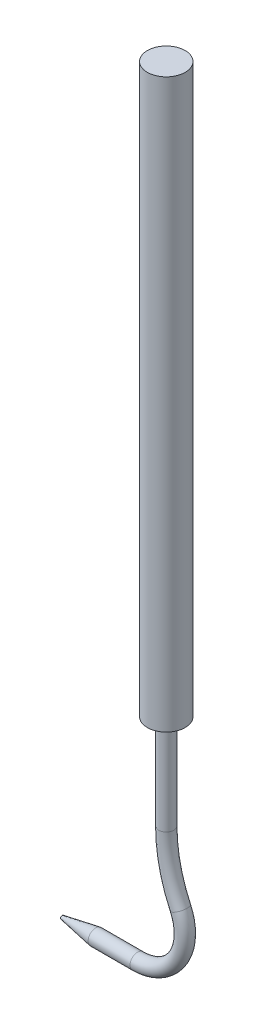
from build123d import *

# Parameters (mm, degrees)
SKETCH2_R               = 0.5
CUT_EXTRUDE1_DEPTH      = 4.052867504
CUT_EXTRUDE1_DEPTH_BACK = 4.052867504
SKETCH3_R               = 0.4
SKETCH5_R               = 1
BOSS_EXTRUDE1_DEPTH     = 30


with BuildPart() as part:
    # Sketch1 → Revolve1 (revolve)
    with BuildSketch(Plane.XY, mode=Mode.PRIVATE) as revolve1_sk:
        Polygon((0, 0), (3, 0), (3, -0.4), (2.268512728, -0.4), align=None)
    revolve(revolve1_sk.sketch.rotate(Axis((0, 0, 0), (-1, 0, 0)), 180), axis=Axis((0, 0, 0), (-1, 0, 0)))

    # Sketch2 → Cut-Extrude1 (cut, two sides)
    with BuildSketch(Plane(origin=(0, 0, 0), x_dir=(1, 0, 0), z_dir=(0, 1, 0))) as cut_extrude1_sk:
        Circle(SKETCH2_R)
    extrude(amount=CUT_EXTRUDE1_DEPTH, mode=Mode.SUBTRACT)
    extrude(cut_extrude1_sk.sketch, amount=-CUT_EXTRUDE1_DEPTH_BACK, mode=Mode.SUBTRACT)

    # Sweep1: sweep along a path in Sketch4
    with BuildLine(Plane.XY) as sweep1_path:
        Line((3, 0), (4.483768236, 0))
        ThreePointArc((4.483768236, 0), (6.592246851, 1.156750979), (6.749537704, 3.556545654))
        ThreePointArc((6.749537704, 3.556545654), (6.189631943, 5.205974837), (6, 6.937491748))
        Line((6, 6.937491748), (6, 11.937491748))
    # Sketch3 → Sweep1 (sweep)
    with BuildSketch(Plane(origin=(3, 0, 0), x_dir=(0, 0, -1), z_dir=(1, 0, 0))):
        Circle(SKETCH3_R)
    sweep(path=sweep1_path.line)

    # Sketch5 → Boss-Extrude1 (add)
    with BuildSketch(Plane(origin=(0, 11.937491748, 0), x_dir=(-1, 0, 0), z_dir=(0, 1, 0))):
        with Locations((-6, 0)):
            Circle(SKETCH5_R)
    extrude(amount=BOSS_EXTRUDE1_DEPTH)


solid = part.part
